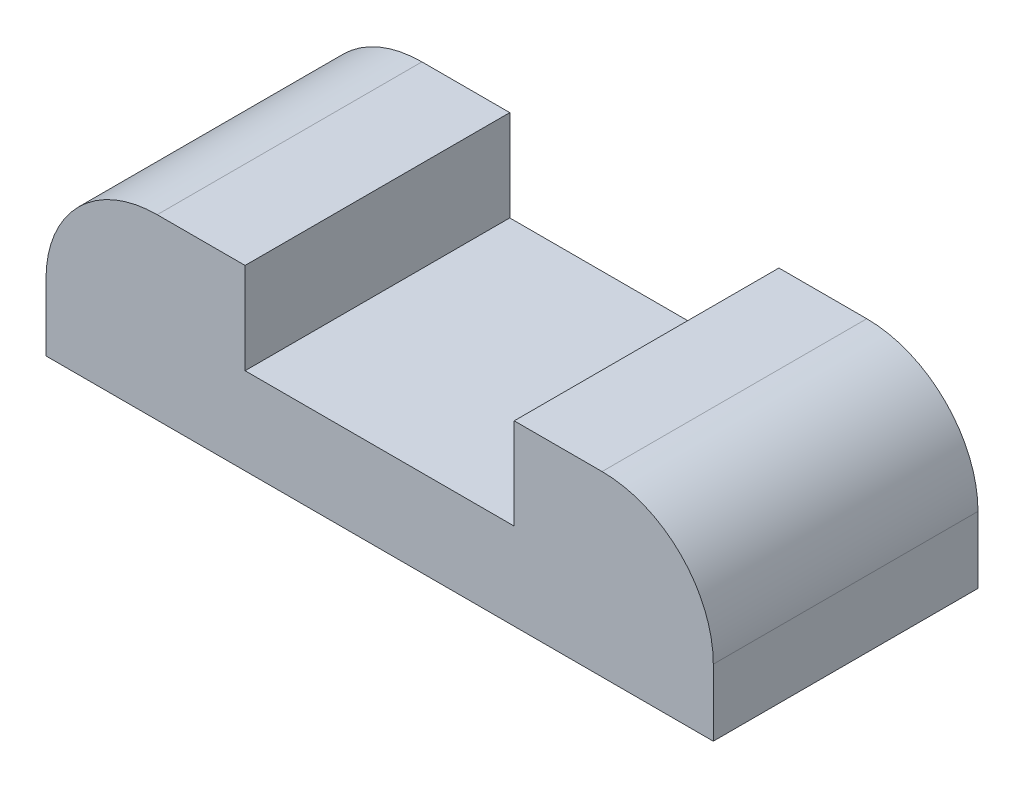
from build123d import *

# Parameters (mm, degrees)
SKETCH1_W           = 30
SKETCH1_H           = 11.9
BOSS_EXTRUDE1_DEPTH = 8
SKETCH3_W           = 12.1
SKETCH3_H           = 11.9
CUT_EXTRUDE1_DEPTH  = 4.1
FILLET1_R           = 5


with BuildPart() as part:
    # Sketch1 → Boss-Extrude1 (new body)
    with BuildSketch(Plane(origin=(0, 0, 0), x_dir=(1, 0, 0), z_dir=(0, 1, 0))):
        Rectangle(SKETCH1_W, SKETCH1_H)
    extrude(amount=BOSS_EXTRUDE1_DEPTH)

    # Sketch3 → Cut-Extrude1 (cut)
    with BuildSketch(Plane(origin=(0, 8, 0), x_dir=(1, 0, 0), z_dir=(0, 1, 0))):
        Rectangle(SKETCH3_W, SKETCH3_H)
    extrude(amount=-CUT_EXTRUDE1_DEPTH, mode=Mode.SUBTRACT)

    # Fillet1
    fillet1_edges = [part.edges().sort_by_distance(p)[0] for p in [
        (15, 8, 0),
        (-15, 8, 0),
    ]]
    fillet(fillet1_edges, radius=FILLET1_R)


solid = part.part
